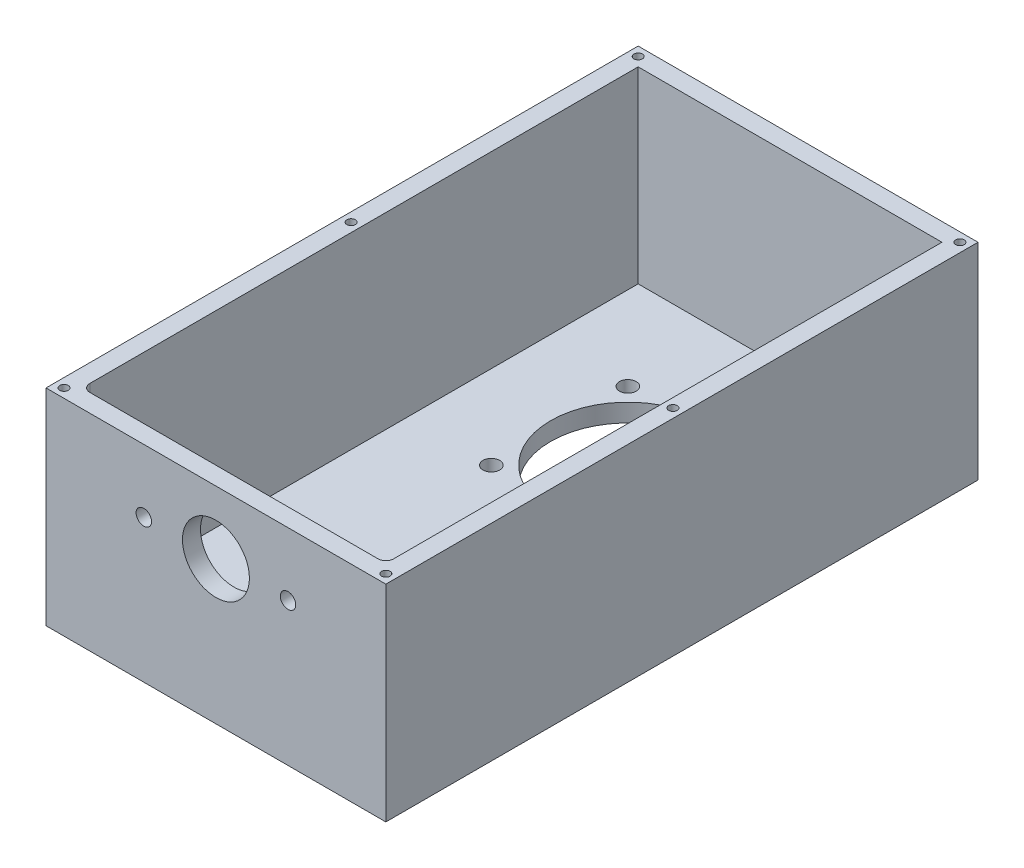
from build123d import *

# Parameters (mm, degrees)
SKETCH_1_W             = 132
SKETCH_1_H             = 80
EXTRUDE_1_DEPTH        = 230
SKETCH_2_W             = 118
SKETCH_2_H             = 216
CUT_EXTRUDE_1_DEPTH    = 73
SKETCH_3_R             = 13
SKETCH_3_R_2           = 3
CUT_EXTRUDE_2_DEPTH    = 10
SKETCH_4_R             = 3.25
SKETCH_4_R_2           = 30
CUT_EXTRUDE_3_DEPTH    = 10
FILLET_1_R             = 3
HOLE_WIZARD_M4_1_D     = 3.3
HOLE_WIZARD_M4_1_DEPTH = 10.1
HOLE_WIZARD_M4_1_TIP   = 0.991420021


with BuildPart() as part:
    # 草图1 → 凸台-拉伸1 (new body)
    with BuildSketch(Plane.XY):
        Rectangle(SKETCH_1_W, SKETCH_1_H)
    extrude(amount=-EXTRUDE_1_DEPTH)

    # 草图2 → 切除-拉伸1 (cut)
    with BuildSketch(Plane(origin=(0, 40, 0), x_dir=(1, 0, 0), z_dir=(0, 1, 0))):
        with Locations((0, 115)):
            Rectangle(SKETCH_2_W, SKETCH_2_H)
    extrude(amount=-CUT_EXTRUDE_1_DEPTH, mode=Mode.SUBTRACT)

    # 草图3 → 切除-拉伸2 (cut)
    with BuildSketch(Plane.XY):
        with Locations((0, 15.5)):
            Circle(SKETCH_3_R)
        with Locations((-28, 15.5)):
            Circle(SKETCH_3_R_2)
        with Locations((28, 15.5)):
            Circle(SKETCH_3_R_2)
    extrude(amount=-CUT_EXTRUDE_2_DEPTH, mode=Mode.SUBTRACT)

    # 草图4 → 切除-拉伸3 (cut)
    with BuildSketch(Plane(origin=(0, -33, 0), x_dir=(1, 0, 0), z_dir=(0, 1, 0))):
        with Locations((26.516504294, 186.516504294)):
            Circle(SKETCH_4_R)
        with Locations((26.516504294, 133.483495706)):
            Circle(SKETCH_4_R)
        with Locations((-26.516504294, 133.483495706)):
            Circle(SKETCH_4_R)
        with Locations((-26.516504294, 186.516504294)):
            Circle(SKETCH_4_R)
        with Locations((0, 160)):
            Circle(SKETCH_4_R_2)
    extrude(amount=-CUT_EXTRUDE_3_DEPTH, mode=Mode.SUBTRACT)

    # 圆角1
    fillet_1_edges = [part.edges().sort_by_distance(p)[0] for p in [
        (-59, 3.5, -7),
        (59, 3.5, -7),
    ]]
    fillet(fillet_1_edges, radius=FILLET_1_R)

    # M4 螺纹孔1
    with Locations(Plane(origin=(-62.5, 40, -226.5), x_dir=(0, 0, 1), z_dir=(0, 1, 0))):
        with Locations((0, 0), (111.5, 0), (111.5, 125), (0, 125), (223, 125), (223, 0)):
            Hole(HOLE_WIZARD_M4_1_D / 2, depth=HOLE_WIZARD_M4_1_DEPTH)
            with Locations((0, 0, -(HOLE_WIZARD_M4_1_DEPTH + HOLE_WIZARD_M4_1_TIP / 2))):  # 118° drill point
                Cone(0, HOLE_WIZARD_M4_1_D / 2, HOLE_WIZARD_M4_1_TIP, mode=Mode.SUBTRACT)


solid = part.part
